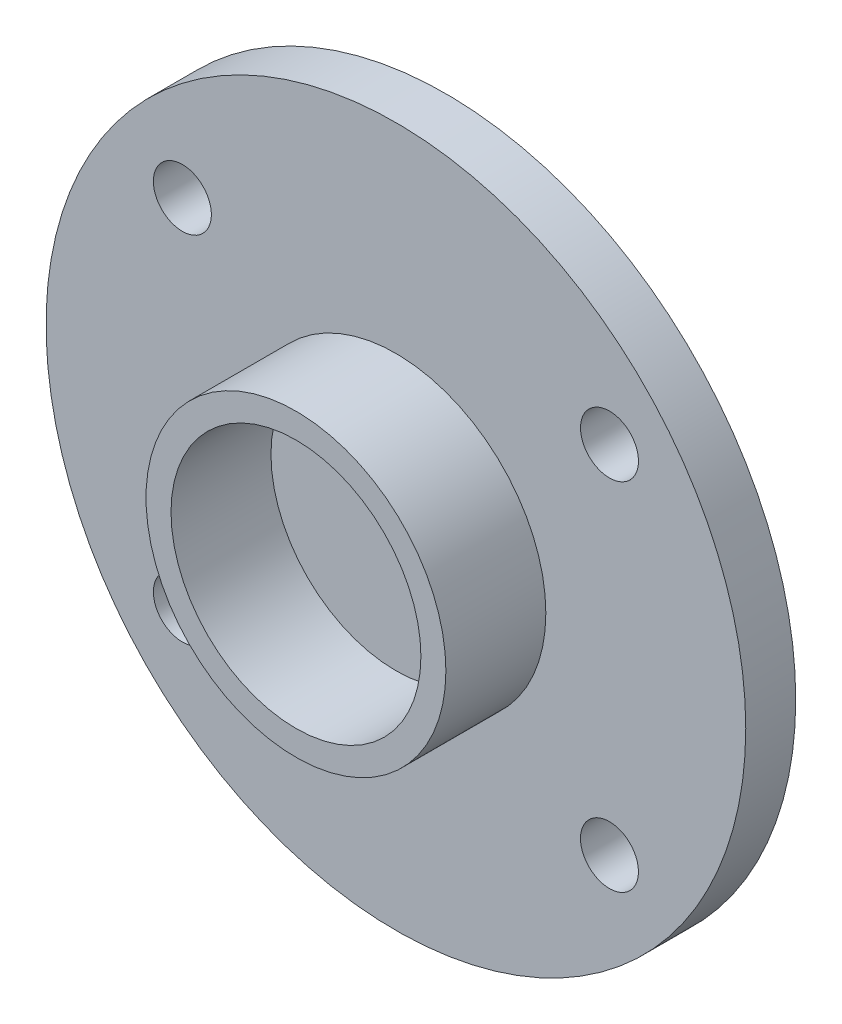
from build123d import *

# Parameters (mm, degrees)
SKETCH2_R           = 7
SKETCH2_R_2         = 0.58
BOSS_EXTRUDE1_DEPTH = 1
SKETCH3_R           = 3
SKETCH3_R_2         = 2.5
EXTRUDE_THIN1_DEPTH = 2


with BuildPart() as part:
    # Sketch2 → Boss-Extrude1 (new body)
    with BuildSketch(Plane.XY):
        Circle(SKETCH2_R)
        with Locations((4.27289846, 3.557518623)):
            Circle(SKETCH2_R_2, mode=Mode.SUBTRACT)
        with Locations((-4.27289846, 3.557518623)):
            Circle(SKETCH2_R_2, mode=Mode.SUBTRACT)
        with Locations((4.27289846, -3.557518623)):
            Circle(SKETCH2_R_2, mode=Mode.SUBTRACT)
        with Locations((-4.27289846, -3.557518623)):
            Circle(SKETCH2_R_2, mode=Mode.SUBTRACT)
    extrude(amount=BOSS_EXTRUDE1_DEPTH)

    # Sketch3 → Extrude-Thin1 (add)
    with BuildSketch(Plane.XY.offset(1)):
        Circle(SKETCH3_R)
        Circle(SKETCH3_R_2, mode=Mode.SUBTRACT)
    extrude(amount=EXTRUDE_THIN1_DEPTH)


solid = part.part
